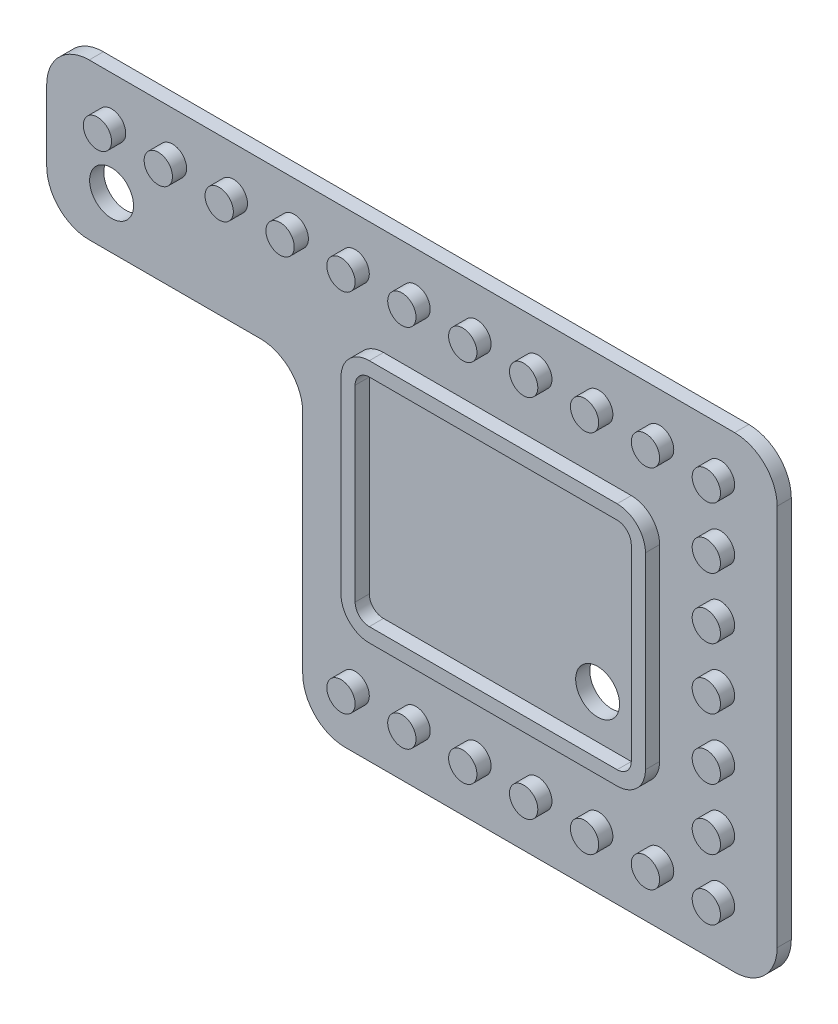
from build123d import *

# Parameters (mm, degrees)
BOSS_EXTRUDE1_DEPTH = 1
SKETCH2_R           = 1
BOSS_EXTRUDE2_DEPTH = 1
FILLET1_R           = 3
CUT_EXTRUDE1_REACH  = 3
SKETCH3_R           = 1.55


with BuildPart() as part:
    # Sketch1 → Boss-Extrude1 (new body)
    with BuildSketch(Plane.XY):
        Polygon((-8, 5), (-8, 38), (-59.580513121, 38), (-59.580513121, 27), (-41.5, 27), (-41.5, 5), align=None)
    extrude(amount=BOSS_EXTRUDE1_DEPTH)

    # Sketch2 → Boss-Extrude2 (add)
    with BuildSketch(Plane.XY.offset(1)):
        with Locations((-12, 9)):
            Circle(SKETCH2_R)
        with Locations((-12, 13.3)):
            Circle(SKETCH2_R)
        with Locations((-12, 17.6)):
            Circle(SKETCH2_R)
        with Locations((-12, 21.9)):
            Circle(SKETCH2_R)
        with Locations((-12, 26.2)):
            Circle(SKETCH2_R)
        with Locations((-12, 30.5)):
            Circle(SKETCH2_R)
        with Locations((-12, 34.8)):
            Circle(SKETCH2_R)
        with Locations((-16.3, 9)):
            Circle(SKETCH2_R)
        with Locations((-20.6, 9)):
            Circle(SKETCH2_R)
        with Locations((-24.9, 9)):
            Circle(SKETCH2_R)
        with Locations((-29.2, 9)):
            Circle(SKETCH2_R)
        with Locations((-33.5, 9)):
            Circle(SKETCH2_R)
        with Locations((-37.8, 9)):
            Circle(SKETCH2_R)
        with Locations((-16.3, 34.8)):
            Circle(SKETCH2_R)
        with Locations((-20.6, 34.8)):
            Circle(SKETCH2_R)
        with Locations((-24.9, 34.8)):
            Circle(SKETCH2_R)
        with Locations((-29.2, 34.8)):
            Circle(SKETCH2_R)
        with Locations((-33.5, 34.8)):
            Circle(SKETCH2_R)
        with Locations((-37.8, 34.8)):
            Circle(SKETCH2_R)
        with Locations((-42.1, 34.8)):
            Circle(SKETCH2_R)
        with Locations((-46.4, 34.8)):
            Circle(SKETCH2_R)
        with Locations((-50.7, 34.8)):
            Circle(SKETCH2_R)
        with Locations((-55, 34.8)):
            Circle(SKETCH2_R)
        with BuildLine():
            Line((-35.8, 30.5), (-18.3, 30.5))
            ThreePointArc((-18.3, 30.5), (-16.885786438, 29.914213562), (-16.3, 28.5))
            Line((-16.3, 28.5), (-16.3, 15.236025644))
            ThreePointArc((-16.3, 15.236025644), (-16.885786438, 13.821812082), (-18.3, 13.236025644))
            Line((-18.3, 13.236025644), (-35.8, 13.236025644))
            ThreePointArc((-35.8, 13.236025644), (-37.214213562, 13.821812082), (-37.8, 15.236025644))
            Line((-37.8, 15.236025644), (-37.8, 28.5))
            ThreePointArc((-37.8, 28.5), (-37.214213562, 29.914213562), (-35.8, 30.5))
        make_face()
        with BuildLine():
            Line((-35.8, 29.5), (-18.3, 29.5))
            ThreePointArc((-18.3, 29.5), (-17.592893219, 29.207106781), (-17.3, 28.5))
            Line((-17.3, 28.5), (-17.3, 15.236025644))
            ThreePointArc((-17.3, 15.236025644), (-17.592893219, 14.528918863), (-18.3, 14.236025644))
            Line((-18.3, 14.236025644), (-35.8, 14.236025644))
            ThreePointArc((-35.8, 14.236025644), (-36.507106781, 14.528918863), (-36.8, 15.236025644))
            Line((-36.8, 15.236025644), (-36.8, 28.5))
            ThreePointArc((-36.8, 28.5), (-36.507106781, 29.207106781), (-35.8, 29.5))
        make_face(mode=Mode.SUBTRACT)
    extrude(amount=BOSS_EXTRUDE2_DEPTH)

    # Fillet1
    fillet1_edges = [part.edges().sort_by_distance(p)[0] for p in [
        (-41.5, 5, 0.5),
        (-41.5, 27, 0.5),
        (-59.580513121, 27, 0.5),
        (-59.580513121, 38, 0.5),
        (-8, 38, 0.5),
        (-8, 5, 0.5),
    ]]
    fillet(fillet1_edges, radius=FILLET1_R)

    # Sketch3 → Cut-Extrude1 (cut, up to next)
    with BuildSketch(Plane.XY.offset(1), mode=Mode.PRIVATE) as cut_extrude1_sk1:
        with Locations((-20.677552724, 17.314204089)):
            Circle(SKETCH3_R)
    cut_extrude1_tool1 = extrude(cut_extrude1_sk1.sketch, amount=-CUT_EXTRUDE1_REACH, mode=Mode.PRIVATE) & part.part
    add(cut_extrude1_tool1.solids().sort_by_distance((-20.677553, 17.314204, 1))[0], mode=Mode.SUBTRACT)
    # Sketch3 → Cut-Extrude1 (cut, up to next)
    with BuildSketch(Plane.XY.offset(1), mode=Mode.PRIVATE) as cut_extrude1_sk2:
        with Locations((-55, 30.651276125)):
            Circle(SKETCH3_R)
    cut_extrude1_tool2 = extrude(cut_extrude1_sk2.sketch, amount=-CUT_EXTRUDE1_REACH, mode=Mode.PRIVATE) & part.part
    add(cut_extrude1_tool2.solids().sort_by_distance((-55, 30.651276, 1))[0], mode=Mode.SUBTRACT)


solid = part.part
